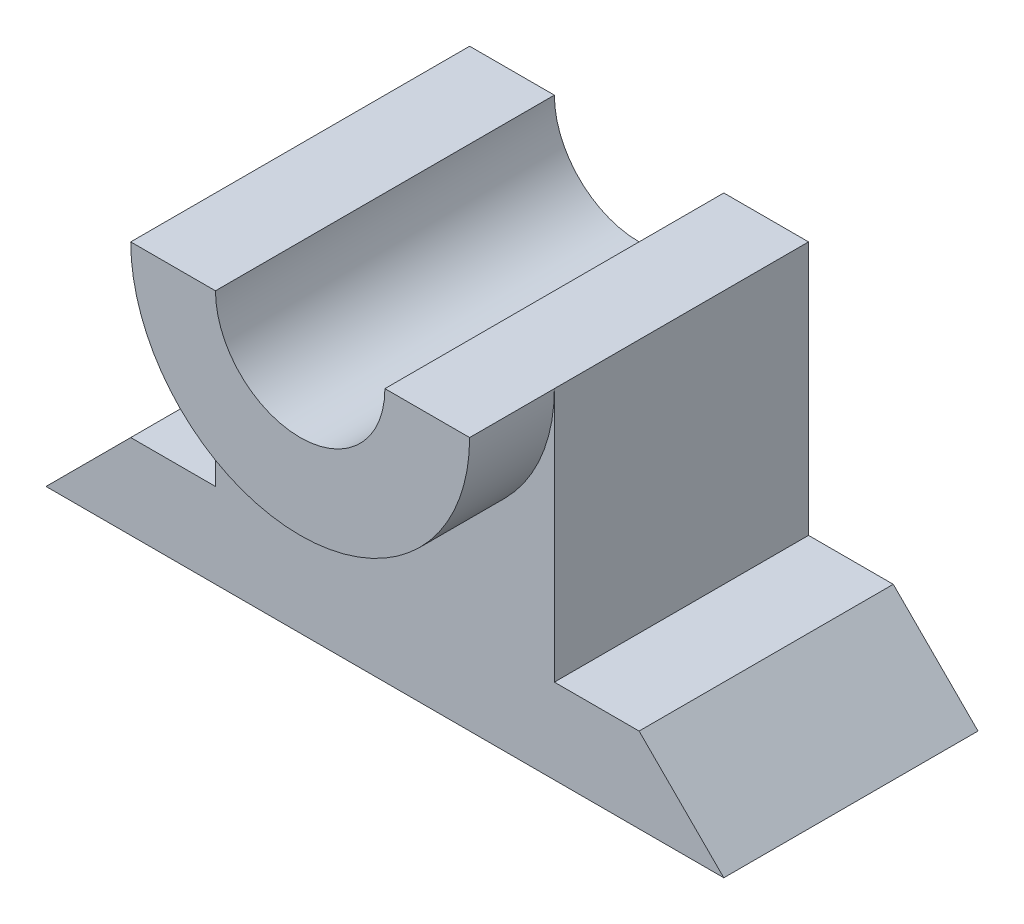
from build123d import *

# Parameters (mm, degrees)
EXTRUDE_1_DEPTH     = 3
EXTRUDE_2_DEPTH     = 4
CUT_EXTRUDE_1_DEPTH = 4


with BuildPart() as part:
    # 草圖1 → 填料-伸長1 (new body)
    with BuildSketch(Plane.XY):
        Polygon((0, 0), (4, 0), (3, 1), (2, 1), (2, 4), (0, 4), align=None)
    extrude_1 = extrude(amount=EXTRUDE_1_DEPTH)

    # 草圖2 → 填料-伸長2 (add)
    with BuildSketch(Plane.XY):
        with BuildLine():
            ThreePointArc((0, 2), (1.414213562, 2.585786438), (2, 4))
            Line((2, 4), (1, 4))
            ThreePointArc((1, 4), (0.707106781, 3.292893219), (0, 3))
            Line((0, 3), (0, 2))
        make_face()
    extrude_2 = extrude(amount=EXTRUDE_2_DEPTH)

    # 草圖2<3> → 除料-伸長1 (cut)
    with BuildSketch(Plane.XY):
        with BuildLine():
            ThreePointArc((0, 3), (0.707106781, 3.292893219), (1, 4))
            Line((1, 4), (0, 4))
            Line((0, 4), (0, 3))
        make_face()
    cut_extrude_1 = extrude(amount=CUT_EXTRUDE_1_DEPTH, mode=Mode.SUBTRACT)

    # 鏡射1: 填料-伸長1, 填料-伸長2, 除料-伸長1 across plane
    add(extrude_1.mirror(Plane(origin=(0, 0, 0), x_dir=(0, 0, 1), z_dir=(1, 0, 0))))
    add(extrude_2.mirror(Plane(origin=(0, 0, 0), x_dir=(0, 0, 1), z_dir=(1, 0, 0))))
    add(cut_extrude_1.mirror(Plane(origin=(0, 0, 0), x_dir=(0, 0, 1), z_dir=(1, 0, 0))), mode=Mode.SUBTRACT)


solid = part.part
